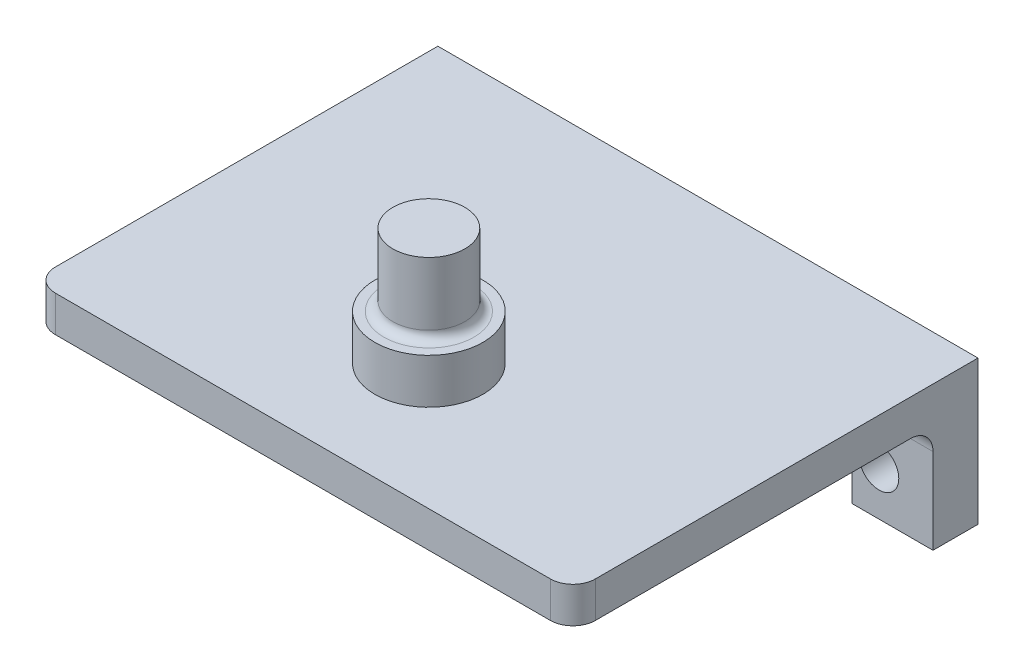
from build123d import *

# Parameters (mm, degrees)
SKETCH1_W           = 60
SKETCH1_H           = 4
BOSS_EXTRUDE1_DEPTH = 45
SKETCH1_3_W         = 9
SKETCH1_3_H         = 24
SKETCH1_3_R         = 2.2
BOSS_EXTRUDE2_DEPTH = 5
SKETCH2_R           = 3
SKETCH2_R_2         = 1.6
CUT_EXTRUDE1_DEPTH  = 124.088359511
BOSS_EXTRUDE3_DEPTH = 45
FILLET1_R           = 2.5
FILLET3_R           = 2.5
SKETCH3_R           = 4
BOSS_EXTRUDE4_DEPTH = 13
SKETCH4_R           = 6
BOSS_EXTRUDE5_DEPTH = 5
FILLET4_R           = 1
SKETCH6_W           = 45
SKETCH6_H           = 16
CUT_EXTRUDE2_DEPTH  = 90.416141614


with BuildPart() as part:
    # Sketch1 → Boss-Extrude1 (new body)
    with BuildSketch(Plane.XY):
        with Locations((-82.025641026, 5.685176195)):
            Rectangle(SKETCH1_W, SKETCH1_H)
    extrude(amount=BOSS_EXTRUDE1_DEPTH)

    # Sketch1_3 → Boss-Extrude2 (add)
    # profile 1 of 2: a face of its own
    with BuildSketch(Plane.XY):
        with Locations((-107.525641026, 19.685176195)):
            Rectangle(SKETCH1_3_W, SKETCH1_3_H)
        with Locations((-106.025641026, 14.685176195)):
            Circle(SKETCH1_3_R, mode=Mode.SUBTRACT)
        with Locations((-106.025641026, 24.685176195)):
            Circle(SKETCH1_3_R, mode=Mode.SUBTRACT)
    # profile 2 of 2: a face of its own
    with BuildSketch(Plane.XY):
        with Locations((-56.525641026, 19.685176195)):
            Rectangle(SKETCH1_3_W, SKETCH1_3_H)
        with Locations((-58.025641026, 14.685176195)):
            Circle(SKETCH1_3_R, mode=Mode.SUBTRACT)
        with Locations((-58.025641026, 24.685176195)):
            Circle(SKETCH1_3_R, mode=Mode.SUBTRACT)
    extrude(amount=BOSS_EXTRUDE2_DEPTH)

    # Sketch2 → Cut-Extrude1 (cut, through all)
    with BuildSketch(Plane(origin=(0, 7.685176195, 0), x_dir=(1, 0, 0), z_dir=(0, 1, 0))):
        with Locations((-82.025641026, -31)):
            Circle(SKETCH2_R)
        with Locations((-77.025641026, -26)):
            Circle(SKETCH2_R_2)
        with Locations((-87.025641026, -26)):
            Circle(SKETCH2_R_2)
        with Locations((-77.025641026, -36)):
            Circle(SKETCH2_R_2)
        with Locations((-87.025641026, -36)):
            Circle(SKETCH2_R_2)
    extrude(amount=-CUT_EXTRUDE1_DEPTH, mode=Mode.SUBTRACT)

    # Sketch1_4 → Boss-Extrude3 (add)
    with BuildSketch(Plane.XY):
        Polygon((-112.025641026, 35.685176195), (-112.025641026, 31.685176195), (-103.025641026, 31.685176195), (-61.025641026, 31.685176195), (-52.025641026, 31.685176195), (-52.025641026, 35.685176195), align=None)
    extrude(amount=BOSS_EXTRUDE3_DEPTH)

    # Fillet1
    fillet1_edges = [part.edges().sort_by_distance(p)[0] for p in [
        (-52.025641026, 5.685176195, 45),
        (-112.025641026, 5.685176195, 45),
        (-52.025641026, 33.685176195, 45),
        (-112.025641026, 33.685176195, 45),
    ]]
    fillet(fillet1_edges, radius=FILLET1_R)

    # Fillet3
    fillet3_edges = [part.edges().sort_by_distance(p)[0] for p in [
        (-107.525641026, 7.685176195, 5),
        (-56.525641026, 7.685176195, 5),
        (-56.525641026, 31.685176195, 5),
        (-107.525641026, 31.685176195, 5),
    ]]
    fillet(fillet3_edges, radius=FILLET3_R)

    # Sketch3 → Boss-Extrude4 (add)
    with BuildSketch(Plane(origin=(0, 35.685176195, 0), x_dir=(1, 0, 0), z_dir=(0, 1, 0))):
        with Locations((-82.025641026, -31)):
            Circle(SKETCH3_R)
    extrude(amount=BOSS_EXTRUDE4_DEPTH)

    # Sketch4 → Boss-Extrude5 (add)
    with BuildSketch(Plane(origin=(0, 35.685176195, 0), x_dir=(1, 0, 0), z_dir=(0, 1, 0))):
        with Locations((-82.025641026, -31)):
            Circle(SKETCH4_R)
    extrude(amount=BOSS_EXTRUDE5_DEPTH)

    # Fillet4
    fillet4_edges = [part.edges().sort_by_distance(p)[0] for p in [
        (-86.025641026, 40.685176195, 31),
    ]]
    fillet(fillet4_edges, radius=FILLET4_R)

    # Sketch6 → Cut-Extrude2 (cut, through all)
    with BuildSketch(Plane(origin=(-52.025641026, 0, 0), x_dir=(0, 0, -1), z_dir=(1, 0, 0))):
        with Locations((-22.5, 11.685176195)):
            Rectangle(SKETCH6_W, SKETCH6_H)
    extrude(amount=-CUT_EXTRUDE2_DEPTH, mode=Mode.SUBTRACT)


solid = part.part
